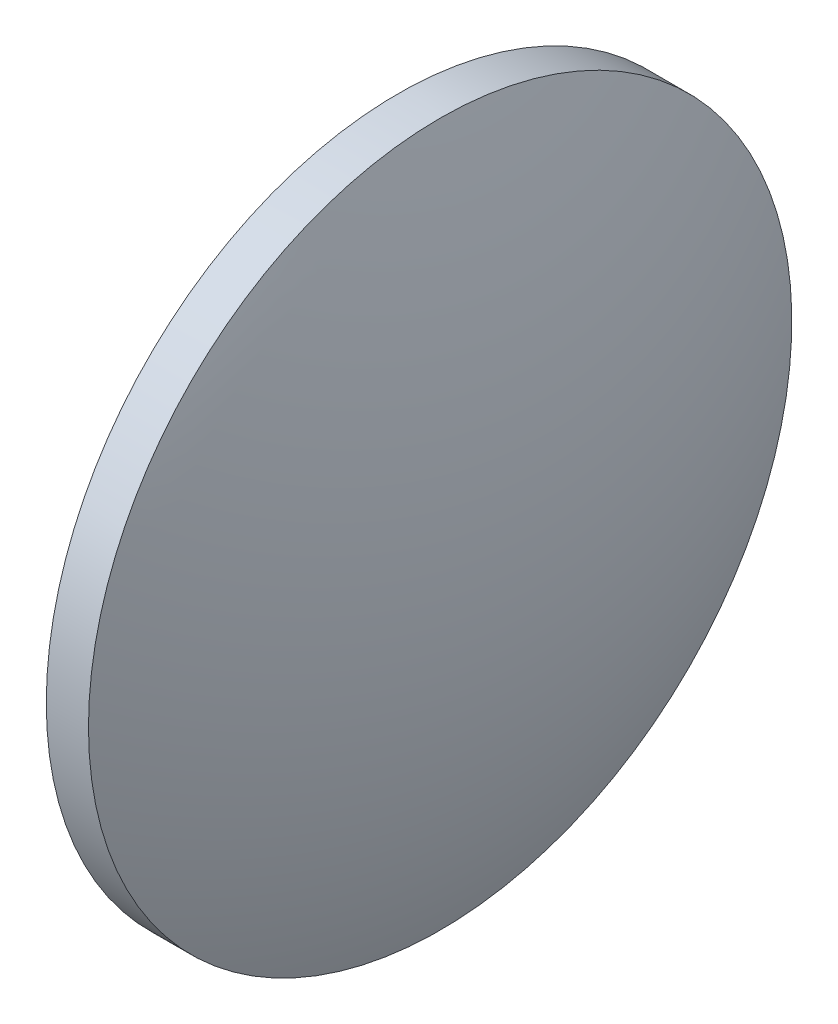
from build123d import *


with BuildPart() as part:
    # 草图1 → 旋转1 (revolve)
    with BuildSketch(Plane.XY):
        with BuildLine():
            Line((549.662815003, 7.574565257), (549.662815003, 20.074565257))
            Line((549.662815003, 20.074565257), (551.162815003, 20.074565257))
            ThreePointArc((551.162815003, 20.074565257), (553.031686962, 13.948339649), (553.662815003, 7.574565257))
            Line((553.662815003, 7.574565257), (549.662815003, 7.574565257))
        make_face()
    revolve(axis=Axis((547.633707424, 7.574565257, 0), (1, 0, 0)))


solid = part.part
